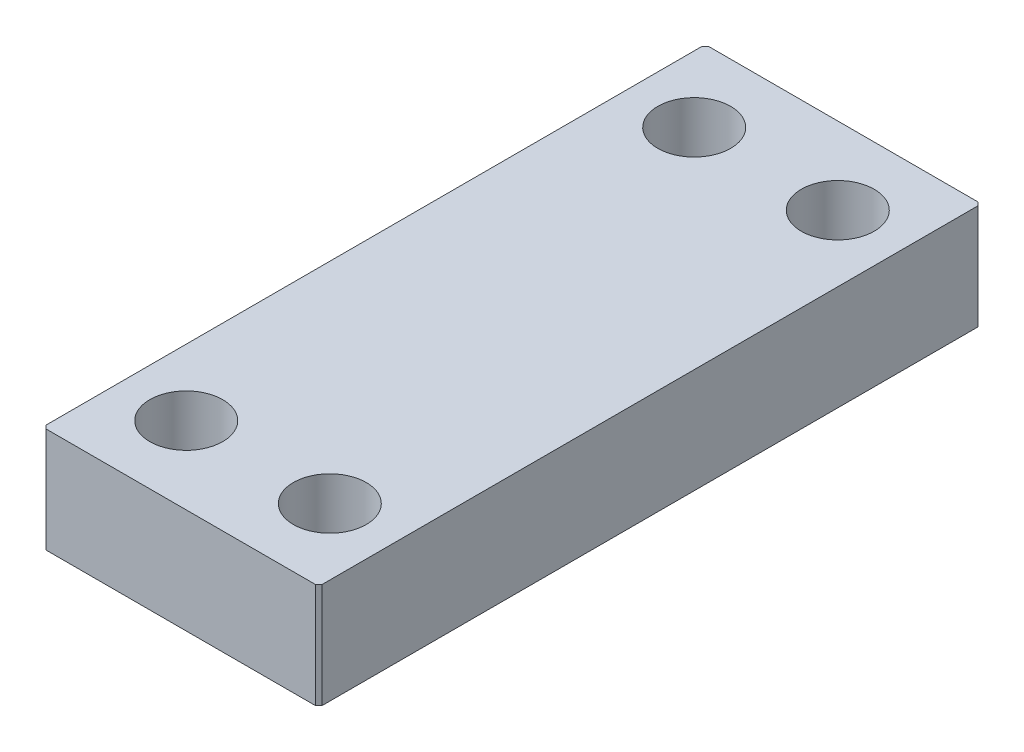
from build123d import *

# Parameters (mm, degrees)
SKETCH1_W           = 25
SKETCH1_H           = 60
SKETCH1_R           = 3.3
BOSS_EXTRUDE1_DEPTH = 9.5
CHAMFER1_SIZE       = 0.3


with BuildPart() as part:
    # Sketch1 → Boss-Extrude1 (new body)
    with BuildSketch(Plane(origin=(0, 0, 0), x_dir=(1, 0, 0), z_dir=(0, 1, 0))):
        Rectangle(SKETCH1_W, SKETCH1_H)
        with Locations((6.5, 23)):
            Circle(SKETCH1_R, mode=Mode.SUBTRACT)
        with Locations((6.5, -23)):
            Circle(SKETCH1_R, mode=Mode.SUBTRACT)
        with Locations((-6.5, 23)):
            Circle(SKETCH1_R, mode=Mode.SUBTRACT)
        with Locations((-6.5, -23)):
            Circle(SKETCH1_R, mode=Mode.SUBTRACT)
    extrude(amount=BOSS_EXTRUDE1_DEPTH)

    # Chamfer1
    chamfer1_edges = [part.edges().sort_by_distance(p)[0] for p in [
        (-12.5, 4.75, -30),
        (12.5, 4.75, -30),
        (12.5, 4.75, 30),
        (-12.5, 4.75, 30),
    ]]
    chamfer(chamfer1_edges, length=CHAMFER1_SIZE)


solid = part.part
